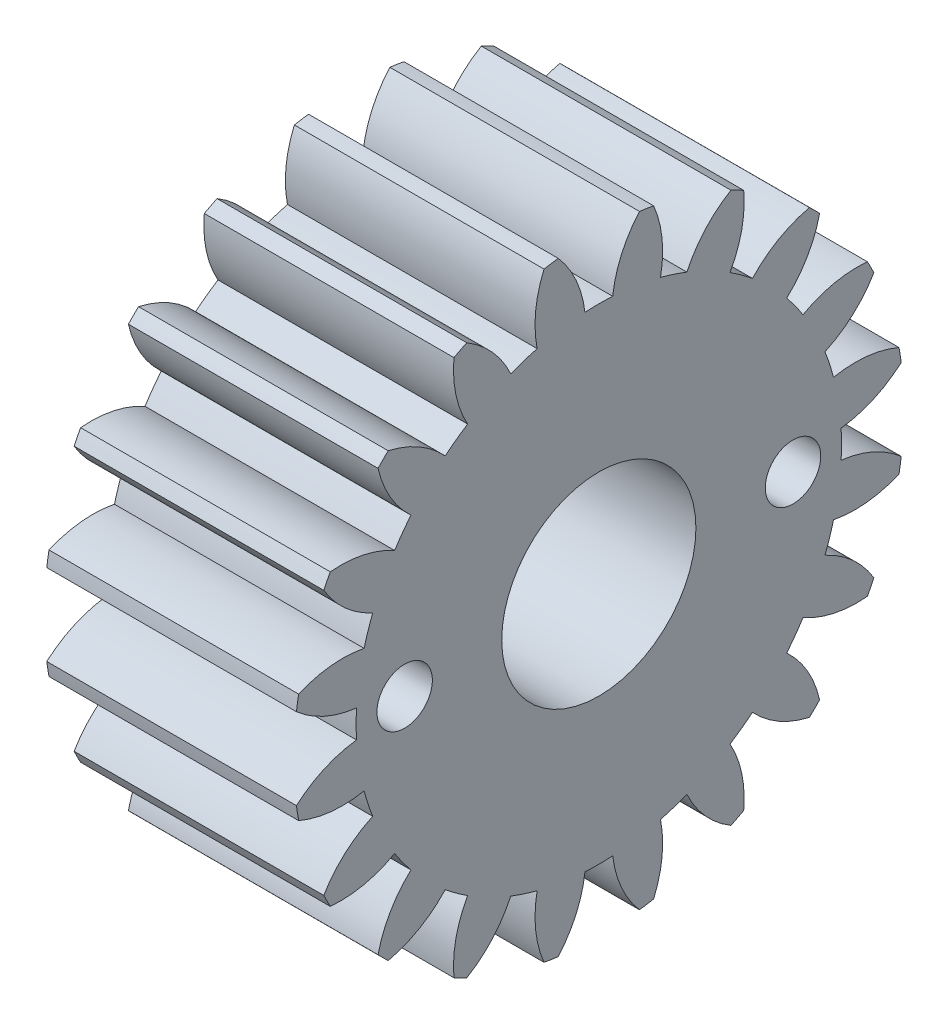
from build123d import *

# Parameters (mm, degrees)
BASPROSKE_W        = 9
BASPROSKE_H        = 11
TOOTHCUT_DEPTH     = 18.972200756
TEETHCUTS_COUNT    = 20
TEETHCUTS_ANGLE    = 342
BORSKE_R           = 3.5
BORE_DEPTH         = 50.0000508
SKETCH1_R          = 1
CUT_EXTRUDE1_DEPTH = 18.852389344


with BuildPart() as part:
    # BasProSke → Base-Revolve (revolve)
    with BuildSketch(Plane(origin=(0, 0, 0), x_dir=(1, 0, 0), z_dir=(0, 1, 0)), mode=Mode.PRIVATE) as base_revolve_sk:
        with Locations((4.5, 5.5)):
            Rectangle(BASPROSKE_W, BASPROSKE_H)
    revolve(base_revolve_sk.sketch.rotate(Axis((-10, 0, 0), (1, 0, 0)), 180), axis=Axis((-10, 0, 0), (1, 0, 0)))

    # TooCutSke → ToothCut (cut, through all)
    with BuildSketch(Plane(origin=(0, 0, 0), x_dir=(0, 0, -1), z_dir=(1, 0, 0))):
        with BuildLine():
            ThreePointArc((0.499924007, 8.734705318), (0, 8.749), (-0.499924007, 8.734705318))
            ThreePointArc((-0.499924007, 8.734705318), (-0.824302243, 9.905497836), (-1.485192705, 10.924909509))
            ThreePointArc((-1.485192705, 10.924909509), (0, 11.0254), (1.485192705, 10.924909509))
            ThreePointArc((1.485192705, 10.924909509), (0.824302243, 9.905497836), (0.499924007, 8.734705318))
        make_face()
    toothcut = extrude(amount=TOOTHCUT_DEPTH, mode=Mode.SUBTRACT)

    # TeethCuts: ToothCut ×20 about axis
    teethcuts_axis = Axis((-10, 0, 0), (1, 0, 0))
    for i in range(1, TEETHCUTS_COUNT):
        add(toothcut.rotate(teethcuts_axis, i * TEETHCUTS_ANGLE / (TEETHCUTS_COUNT - 1)), mode=Mode.SUBTRACT)

    # BorSke → Bore (cut, symmetric)
    with BuildSketch(Plane(origin=(0, 0, 0), x_dir=(0, 0, -1), z_dir=(1, 0, 0))):
        with Locations(Location((0, 0, 0), (0, 0, 180))):
            Circle(BORSKE_R)
    extrude(amount=BORE_DEPTH, both=True, mode=Mode.SUBTRACT)

    # Sketch1 → Cut-Extrude1 (cut, through all)
    with BuildSketch(Plane(origin=(9, 0, 0), x_dir=(0, 0, -1), z_dir=(1, 0, 0))):
        with Locations((-7, 0)):
            Circle(SKETCH1_R)
        with Locations((7, 0)):
            Circle(SKETCH1_R)
    extrude(amount=-CUT_EXTRUDE1_DEPTH, mode=Mode.SUBTRACT)


solid = part.part
